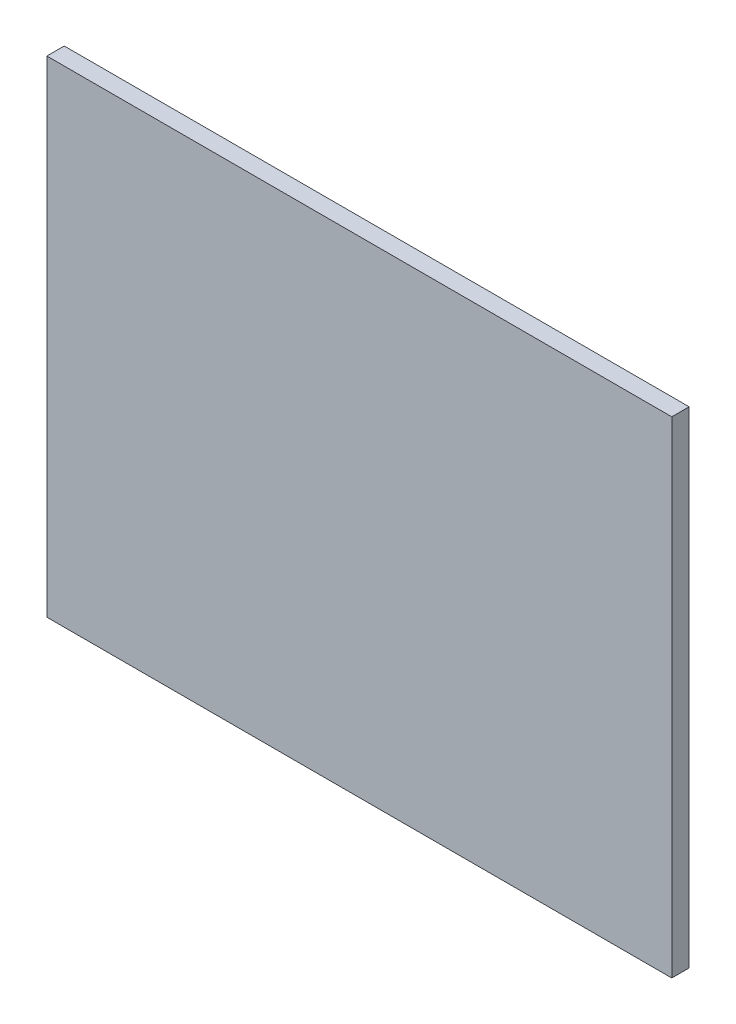
from build123d import *

# Parameters (mm, degrees)
SKETCH1_W           = 180
SKETCH1_H           = 140
BOSS_EXTRUDE1_DEPTH = 5


with BuildPart() as part:
    # Sketch1 → Boss-Extrude1 (new body)
    with BuildSketch(Plane.XY):
        Rectangle(SKETCH1_W, SKETCH1_H)
    extrude(amount=BOSS_EXTRUDE1_DEPTH)


solid = part.part
